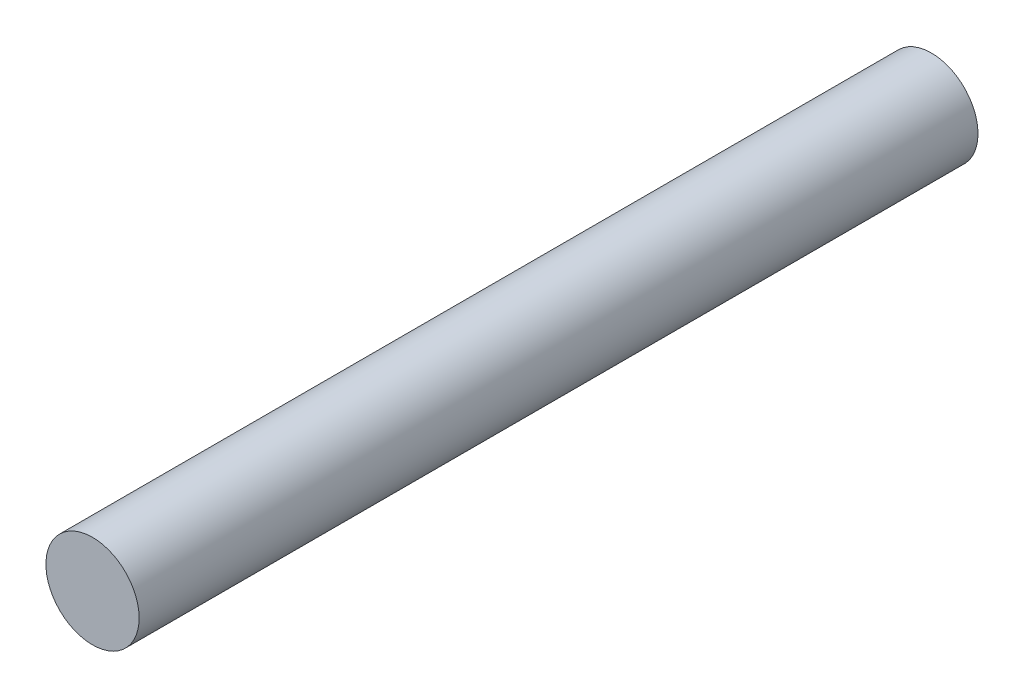
from build123d import *

# Parameters (mm, degrees)
SKETCH1_R           = 1.5875
BOSS_EXTRUDE1_DEPTH = 14.2875


with BuildPart() as part:
    # Sketch1 → Boss-Extrude1 (new body, symmetric)
    with BuildSketch(Plane.XY):
        Circle(SKETCH1_R)
    extrude(amount=BOSS_EXTRUDE1_DEPTH, both=True)


solid = part.part
